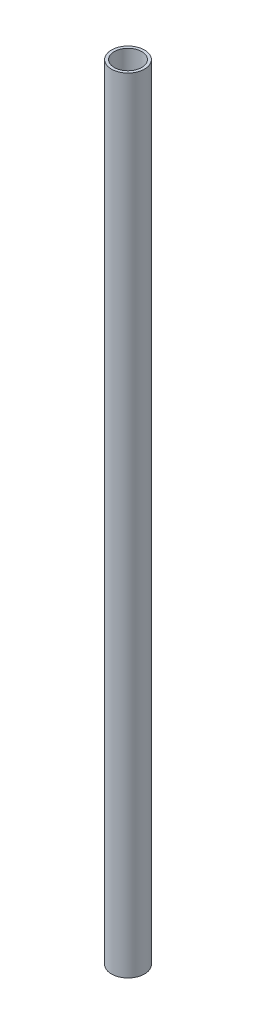
from build123d import *

# Parameters (mm, degrees)
SKETCH1_R           = 21.082
SKETCH1_R_2         = 17.526
BOSS_EXTRUDE1_DEPTH = 996.95


with BuildPart() as part:
    # Sketch1 → Boss-Extrude1 (new body)
    with BuildSketch(Plane(origin=(0, 0, 0), x_dir=(1, 0, 0), z_dir=(0, 1, 0))):
        Circle(SKETCH1_R)
        Circle(SKETCH1_R_2, mode=Mode.SUBTRACT)
    extrude(amount=BOSS_EXTRUDE1_DEPTH)


solid = part.part
